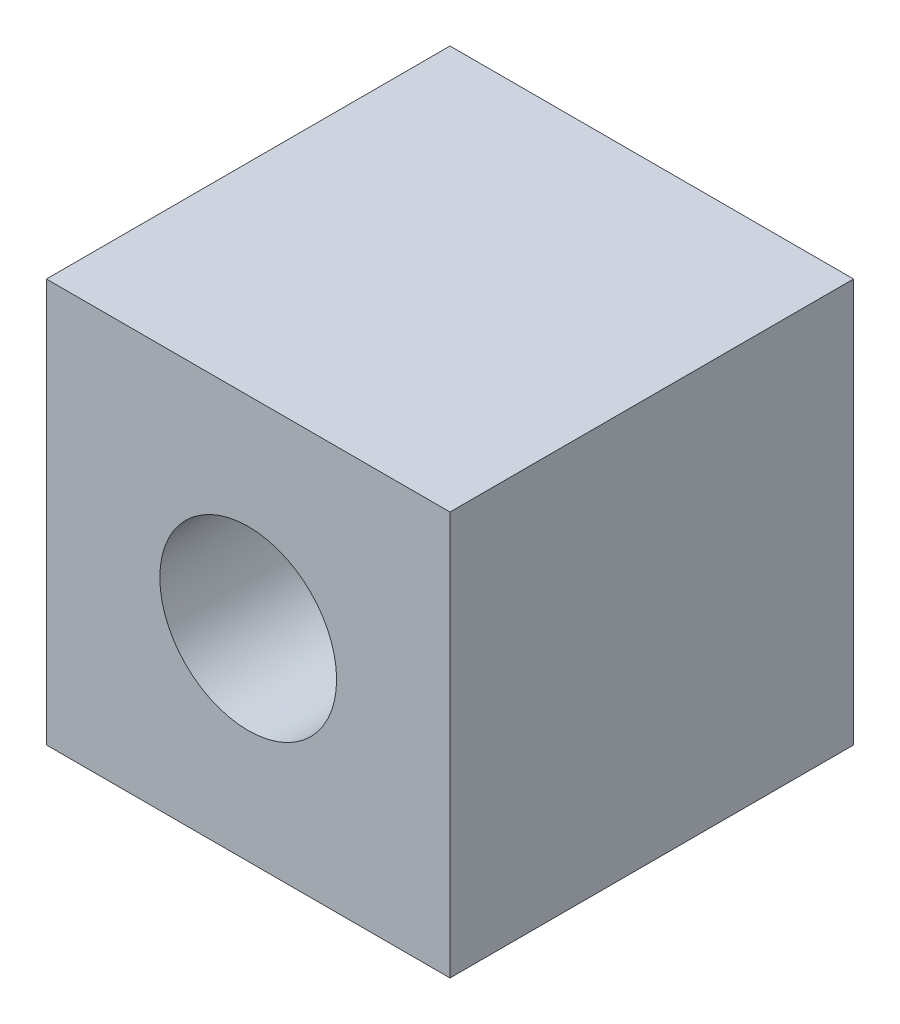
from build123d import *

# Parameters (mm, degrees)
SKETCH1_W           = 25.4
SKETCH1_H           = 25.4
BOSS_EXTRUDE1_DEPTH = 25.4
SKETCH2_R           = 5.5626
CUT_EXTRUDE1_DEPTH  = 76.2


with BuildPart() as part:
    # Sketch1 → Boss-Extrude1 (new body)
    with BuildSketch(Plane(origin=(0, 0, 0), x_dir=(1, 0, 0), z_dir=(0, 1, 0))):
        Rectangle(SKETCH1_W, SKETCH1_H)
    extrude(amount=BOSS_EXTRUDE1_DEPTH)

    # Sketch2 → Cut-Extrude1 (cut)
    with BuildSketch(Plane.XY.offset(12.7)):
        with Locations((0, 12.7)):
            Circle(SKETCH2_R)
    extrude(amount=-CUT_EXTRUDE1_DEPTH, mode=Mode.SUBTRACT)


solid = part.part
